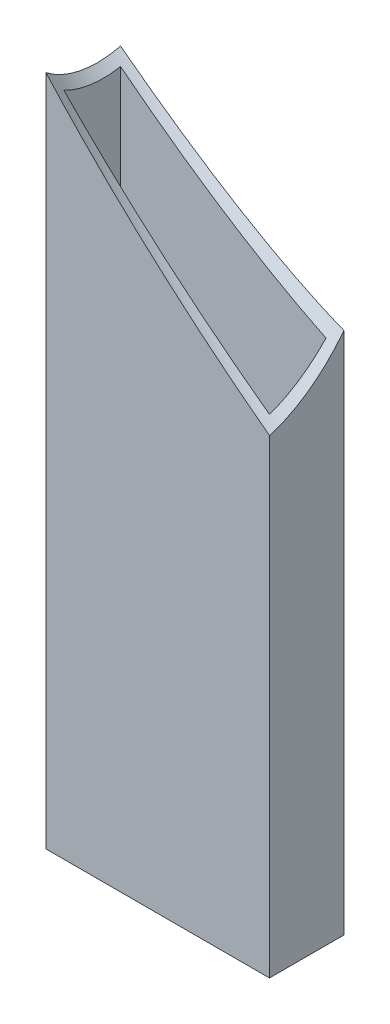
from build123d import *

# Parameters (mm, degrees)
SKETCH1_W           = 76.2
SKETCH1_H           = 25.4
SKETCH1_W_2         = 70.104
SKETCH1_H_2         = 19.304
BOSS_EXTRUDE1_DEPTH = 241.091915
SKETCH3_W           = 76.2
SKETCH3_H           = 25.4
SKETCH3_W_2         = 70.104
SKETCH3_H_2         = 19.304
BOSS_EXTRUDE2_DEPTH = 3.048
CUT_EXTRUDE2_START  = 104.493944
SKETCH5_R           = 38.1
CUT_EXTRUDE2_DEPTH  = 115.162609


with BuildPart() as part:
    # Sketch1 → Boss-Extrude1 (new body)
    with BuildSketch(Plane(origin=(0, 0, 0), x_dir=(1, 0, 0), z_dir=(0, 1, 0))):
        Rectangle(SKETCH1_W, SKETCH1_H)
        Rectangle(SKETCH1_W_2, SKETCH1_H_2, mode=Mode.SUBTRACT)
    extrude(amount=BOSS_EXTRUDE1_DEPTH)

    # Sketch3 → Boss-Extrude2 (add)
    with BuildSketch(Plane(origin=(0, 241.09191526, 0), x_dir=(1, 0, 0), z_dir=(0, 1, 0))):
        Rectangle(SKETCH3_W, SKETCH3_H)
        Rectangle(SKETCH3_W_2, SKETCH3_H_2, mode=Mode.SUBTRACT)
    extrude(amount=BOSS_EXTRUDE2_DEPTH)

    # Sketch5 → Cut-Extrude2 (cut)
    with BuildSketch(Plane(origin=(-101.44355263, 327.150922863, -35.760832037), x_dir=(0.275534909, -0.073492792, -0.958477607), z_dir=(0.736418318, -0.624735905, 0.259601829)).offset(CUT_EXTRUDE2_START)):
        Circle(SKETCH5_R)
    extrude(amount=CUT_EXTRUDE2_DEPTH, mode=Mode.SUBTRACT)


solid = part.part
